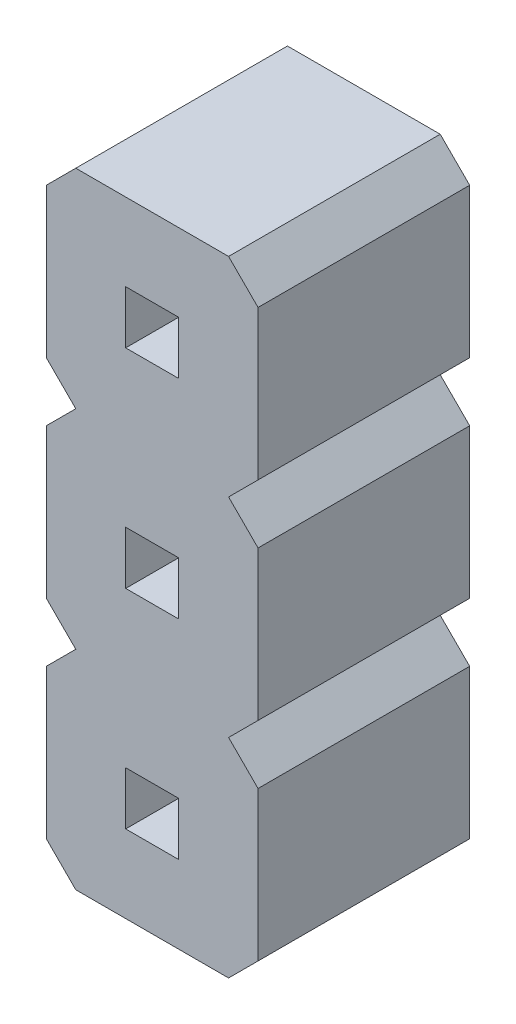
from build123d import *

# Parameters (mm, degrees)
PIN_DRAWING_W       = 0.636
PIN_DRAWING_H       = 0.636
BOSS_EXTRUDE1_DEPTH = 2.54


with BuildPart() as part:
    # pin_drawing → Boss-Extrude1 (new body)
    with BuildSketch(Plane.XY):
        Polygon((0, 2.146446609), (0, 0.353553391), (0.353553391, 0), (0, -0.353553391), (0, -2.146446609), (0.353553391, -2.5), (2.187446609, -2.5), (2.541, -2.146446609), (2.541, -0.353553391), (2.187446609, 0), (2.541, 0.353553391), (2.541, 2.146446609), (2.187446609, 2.5), (2.541, 2.853553391), (2.541, 4.646446609), (2.187446609, 5), (0.353553391, 5), (0, 4.646446609), (0, 2.853553391), (0.353553391, 2.5), align=None)
        with Locations((1.2705, -1.25)):
            Rectangle(PIN_DRAWING_W, PIN_DRAWING_H, mode=Mode.SUBTRACT)
        with Locations((1.2705, 1.25)):
            Rectangle(PIN_DRAWING_W, PIN_DRAWING_H, mode=Mode.SUBTRACT)
        with Locations((1.2705, 3.75)):
            Rectangle(PIN_DRAWING_W, PIN_DRAWING_H, mode=Mode.SUBTRACT)
    extrude(amount=BOSS_EXTRUDE1_DEPTH)


solid = part.part
